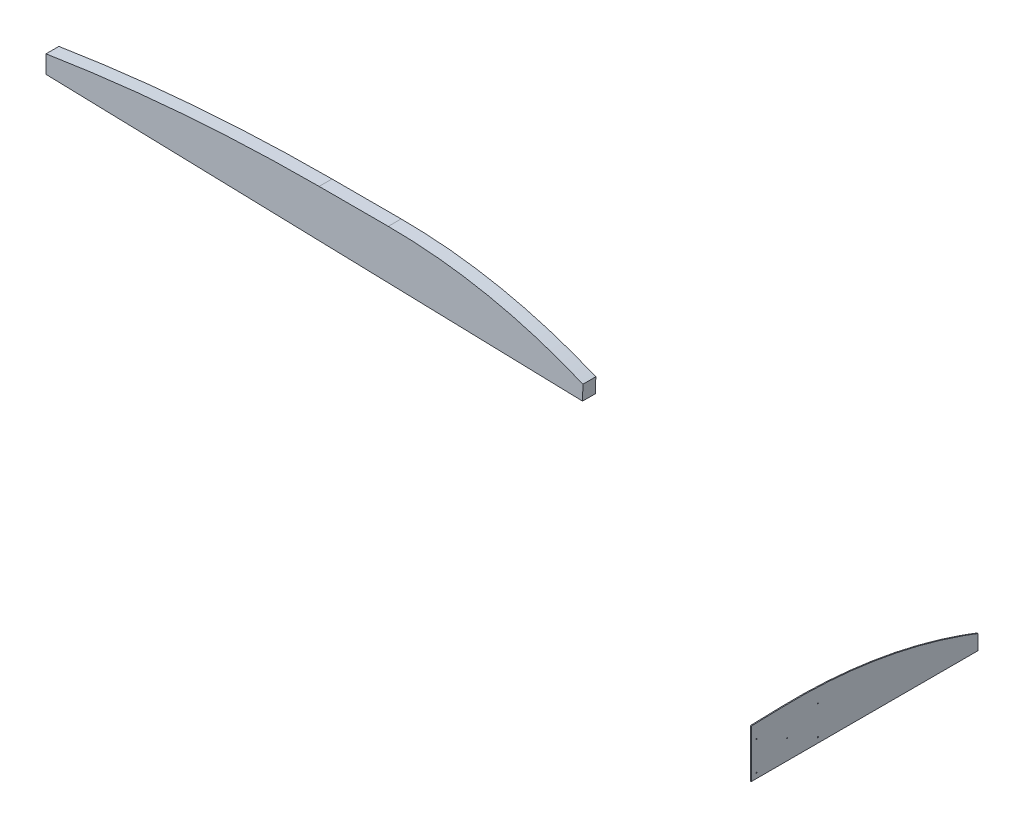
from build123d import *

# Parameters (mm, degrees)
BOSS_EXTRUDE1_DEPTH = 127
SKETCH2_R           = 4.7625
BOSS_EXTRUDE2_DEPTH = 9.398


with BuildPart() as part:
    # Sketch1 → Boss-Extrude1 (new body)
    with BuildSketch(Plane.XY):
        with BuildLine():
            Line((-6816.501384736, 2864.308180535), (-6816.501384736, 2688.917247583))
            Line((-6816.501384736, 2688.917247583), (-1527.214280962, 2543.485601502))
            Line((-1527.214280962, 2543.485601502), (-1523.180364096, 2690.197441952))
            ThreePointArc((-1523.180364096, 2690.197441952), (-2463.193969456, 2980.452507773), (-3442.101384736, 3078.502769387))
            Line((-3442.101384736, 3078.502769387), (-4124.101384736, 3078.502769387))
            ThreePointArc((-4124.101384736, 3078.502769387), (-5474.554742122, 3024.869661361), (-6816.501384736, 2864.308180535))
        make_face()
    extrude(amount=BOSS_EXTRUDE1_DEPTH)


with BuildPart() as body_2:
    # Sketch2 → Boss-Extrude2 (new body)
    with BuildSketch(Plane(origin=(0, 0, 0), x_dir=(0, 0, -1), z_dir=(1, 0, 0))):
        with BuildLine():
            Line((0.004738377, 473.759742407), (306.336040574, 482.182478791))
            ThreePointArc((306.336040574, 482.182478791), (1207.374867605, 424.340411932), (2082.799998861, 203.325679209))
            Line((2082.799998861, 203.325679209), (2082.799998861, 167.187967798))
            Line((2082.799998861, 167.187967798), (2083.053998861, 167.187967798))
            Line((2083.053998861, 167.187967798), (2083.053998861, 203.236138383))
            ThreePointArc((2083.053998861, 203.236138383), (2159.361491956, 175.626305447), (2235.204738323, 146.76563398))
            Line((2235.204738323, 146.76563398), (2235.204738377, -0.001670525))
            Line((2235.204738377, -0.001670525), (0.004738377, -0.001670525))
            Line((0.004738377, -0.001670525), (0.004738377, 473.759742407))
        make_face()
        with Locations((656.356957587, 337.933597897)):
            Circle(SKETCH2_R, mode=Mode.SUBTRACT)
        with Locations((656.356957587, 50.8)):
            Circle(SKETCH2_R, mode=Mode.SUBTRACT)
        with Locations((50.8, 50.8)):
            Circle(SKETCH2_R, mode=Mode.SUBTRACT)
        with Locations((50.8, 337.933597897)):
            Circle(SKETCH2_R, mode=Mode.SUBTRACT)
        with Locations((353.578478793, 194.366798948)):
            Circle(SKETCH2_R, mode=Mode.SUBTRACT)
        Polygon((494.514909268, 176.24223961), (486.022286641, 176.24223961), (486.022286641, 170.238877268), (490.197009742, 170.238877268), (490.197009742, 169.957548154), (486.022286641, 169.957548154), (486.022286641, 163.816033122), (485.730910059, 163.816033122), (485.730910059, 176.516033122), (494.514909268, 176.516033122), align=None, mode=Mode.SUBTRACT)
    extrude(amount=BOSS_EXTRUDE2_DEPTH)


solid = Compound([part.part, body_2.part])
